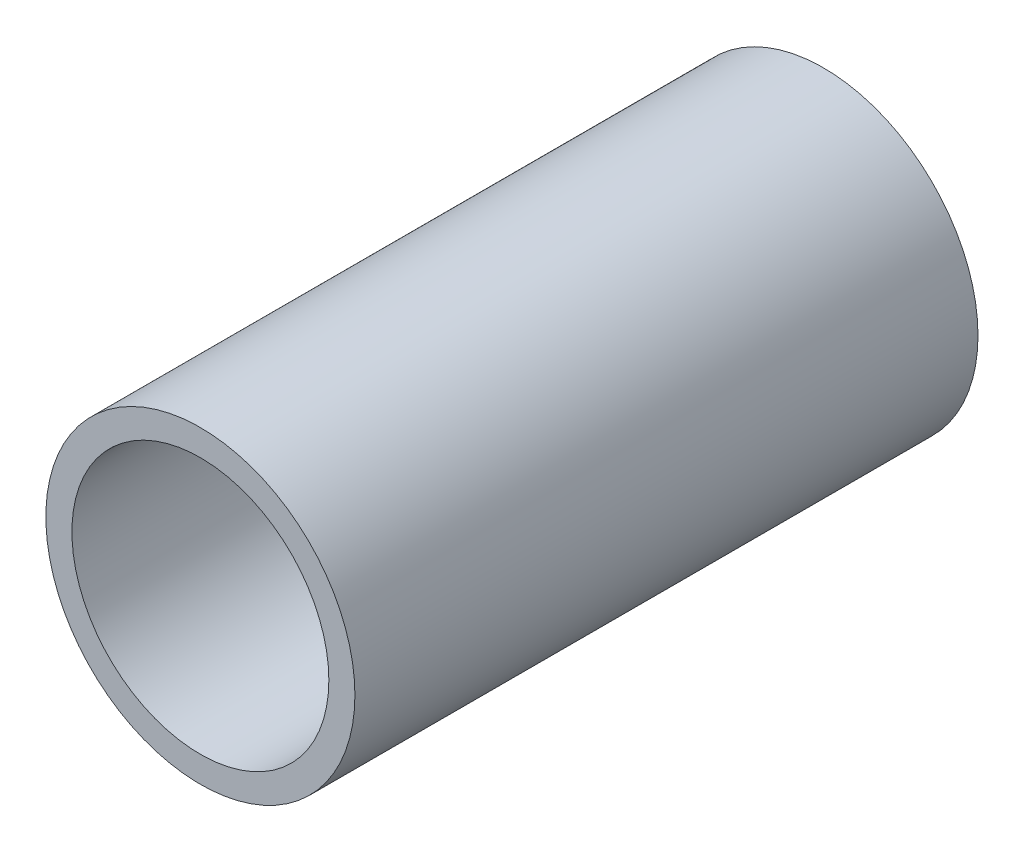
from build123d import *

# Parameters (mm, degrees)
SKETCH1_R           = 21.082
SKETCH1_R_2         = 17.526
EXTRUDE_THIN1_DEPTH = 42.5


with BuildPart() as part:
    # Sketch1 → Extrude-Thin1 (new body, symmetric)
    with BuildSketch(Plane.XY):
        Circle(SKETCH1_R)
        Circle(SKETCH1_R_2, mode=Mode.SUBTRACT)
    extrude(amount=EXTRUDE_THIN1_DEPTH, both=True)


solid = part.part
